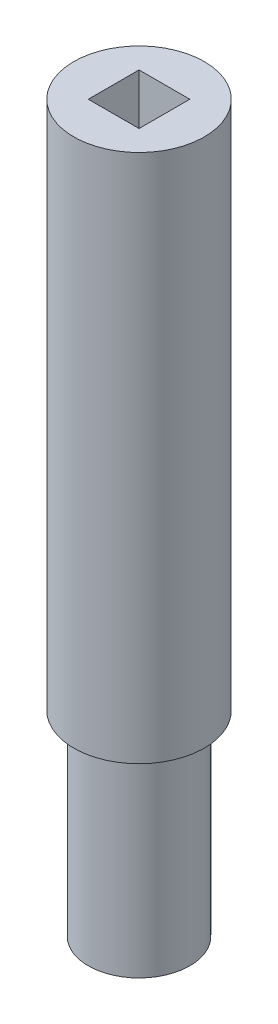
from build123d import *

# Parameters (mm, degrees)
SKETCH_2_W          = 7
SKETCH_2_H          = 7
CUT_EXTRUDE_1_DEPTH = 35
CUT_EXTRUDE_2_DEPTH = 3


with BuildPart() as part:
    # 草图1 → 旋转1 (revolve)
    with BuildSketch(Plane.XY):
        Polygon((0, 0), (-7, 0), (-7, 27), (-9, 27), (-9, 100), (0, 100), align=None)
    revolve(axis=Axis((0, 0, 0), (0, 1, 0)))

    # 草图2 → 切除-拉伸1 (cut)
    with BuildSketch(Plane(origin=(0, 100, 0), x_dir=(1, 0, 0), z_dir=(0, 1, 0))):
        Rectangle(SKETCH_2_W, SKETCH_2_H)
    extrude(amount=-CUT_EXTRUDE_1_DEPTH, mode=Mode.SUBTRACT)

    # 草图4 → 切除-拉伸2 (cut)
    with BuildSketch(Plane(origin=(0, 0, -7), x_dir=(-1, 0, 0), z_dir=(0, 0, -1))):
        with BuildLine():
            Line((-2.5, 4), (-2.5, 22))
            ThreePointArc((-2.5, 22), (0, 24.5), (2.5, 22))
            Line((2.5, 22), (2.5, 4))
            ThreePointArc((2.5, 4), (0, 1.5), (-2.5, 4))
        make_face()
    extrude(amount=-CUT_EXTRUDE_2_DEPTH, mode=Mode.SUBTRACT)


solid = part.part
